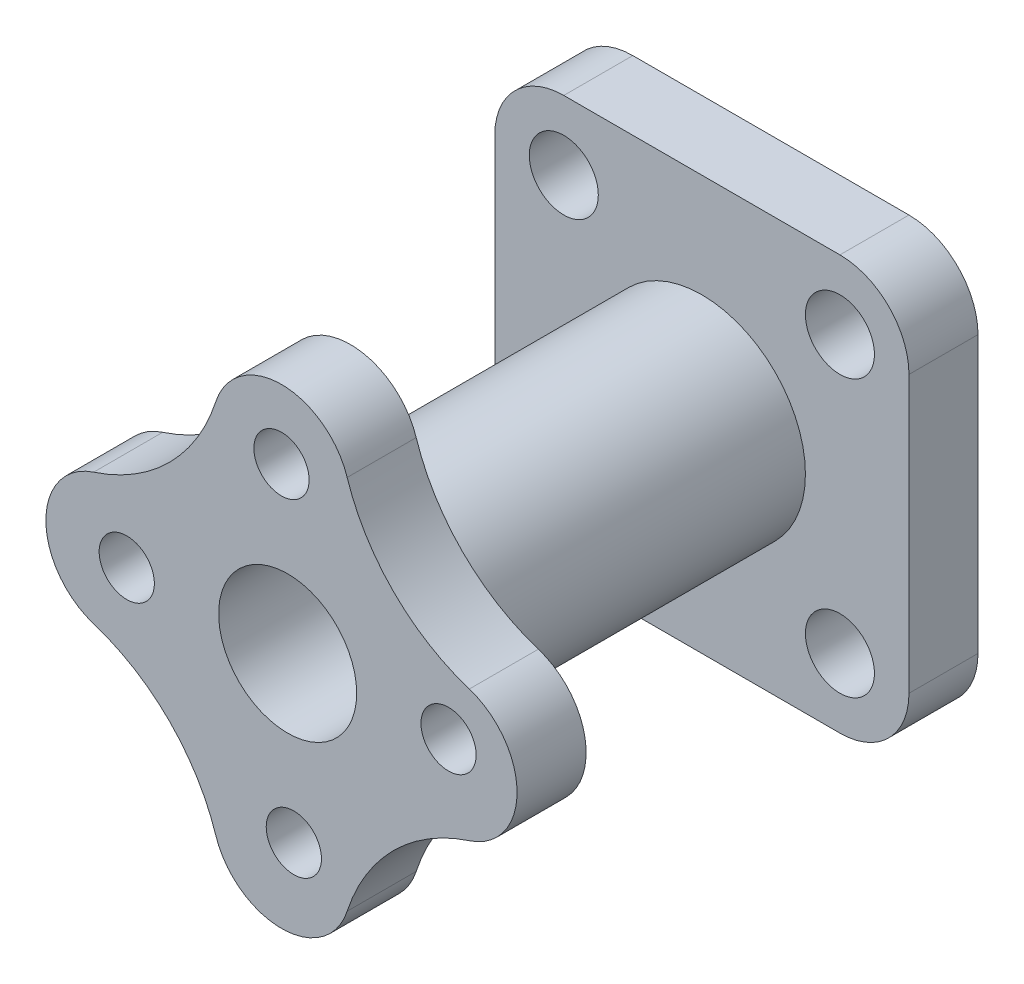
from build123d import *

# Parameters (mm, degrees)
SCHIZZO1_W                   = 120
SCHIZZO1_H                   = 120
ESTRUSIONE_ESTRUSIONE1_DEPTH = 20
SCHIZZO3_R                   = 30
SCHIZZO3_R_2                 = 20
ESTRUSIONE_ESTRUSIONE2_DEPTH = 100
SCHIZZO4_R                   = 20
ESTRUSIONE_ESTRUSIONE3_DEPTH = 20
RACCORDO2_R                  = 20
SCHIZZO8_R                   = 8
TAGLIO_ESTRUSIONE1_DEPTH     = 20
SCHIZZO7_R                   = 10
TAGLIO_ESTRUSIONE2_DEPTH     = 20
RIPETIZIONECIRCOLARE1_COUNT  = 4


with BuildPart() as part:
    # Schizzo1 → Estrusione-Estrusione1 (new body)
    with BuildSketch(Plane.XY):
        Rectangle(SCHIZZO1_W, SCHIZZO1_H)
    extrude(amount=ESTRUSIONE_ESTRUSIONE1_DEPTH)

    # Schizzo3 → Estrusione-Estrusione2 (add)
    with BuildSketch(Plane.XY.offset(20)):
        Circle(SCHIZZO3_R)
        Circle(SCHIZZO3_R_2, mode=Mode.SUBTRACT)
    extrude(amount=ESTRUSIONE_ESTRUSIONE2_DEPTH)

    # Schizzo4 → Estrusione-Estrusione3 (add)
    with BuildSketch(Plane.XY.offset(120)):
        with BuildLine():
            ThreePointArc((-56.205527859, 17.383404463), (-34.252252481, 30.819558816), (-20.816098128, 52.772834194))
            ThreePointArc((-20.816098128, 52.772834194), (-1.788088194, 66.613707799), (17.23992174, 52.772834194))
            ThreePointArc((17.23992174, 52.772834194), (30.676076093, 30.819558816), (52.629351472, 17.383404463))
            ThreePointArc((52.629351472, 17.383404463), (66.470225076, -1.644605471), (52.629351472, -20.672615405))
            ThreePointArc((52.629351472, -20.672615405), (30.676076093, -34.108769758), (17.23992174, -56.062045137))
            ThreePointArc((17.23992174, -56.062045137), (-1.788088194, -69.902918741), (-20.816098128, -56.062045137))
            ThreePointArc((-20.816098128, -56.062045137), (-34.252252481, -34.108769758), (-56.205527859, -20.672615405))
            ThreePointArc((-56.205527859, -20.672615405), (-70.046401464, -1.644605471), (-56.205527859, 17.383404463))
        make_face()
        Circle(SCHIZZO4_R, mode=Mode.SUBTRACT)
    extrude(amount=ESTRUSIONE_ESTRUSIONE3_DEPTH)

    # Raccordo2
    raccordo2_edges = [part.edges().sort_by_distance(p)[0] for p in [
        (-60, 60, 10),
        (60, 60, 10),
        (60, -60, 10),
        (-60, -60, 10),
    ]]
    fillet(raccordo2_edges, radius=RACCORDO2_R)

    # Schizzo8 → Taglio-Estrusione1 (cut)
    with BuildSketch(Plane.XY.offset(140)):
        with Locations((-1.788088194, 46.613707799)):
            Circle(SCHIZZO8_R)
    taglio_estrusione1 = extrude(amount=-TAGLIO_ESTRUSIONE1_DEPTH, mode=Mode.SUBTRACT)

    # Schizzo7 → Taglio-Estrusione2 (cut)
    with BuildSketch(Plane(origin=(0, 0, 0), x_dir=(-1, 0, 0), z_dir=(0, 0, -1))):
        with Locations((-40, 40)):
            Circle(SCHIZZO7_R)
    taglio_estrusione2 = extrude(amount=-TAGLIO_ESTRUSIONE2_DEPTH, mode=Mode.SUBTRACT)

    # RipetizioneCircolare1: Taglio-Estrusione1, Taglio-Estrusione2 ×4 about axis
    ripetizionecircolare1_axis = Axis((0, 0, 0), (0, 0, 1))
    for i in range(1, RIPETIZIONECIRCOLARE1_COUNT):
        add(taglio_estrusione1.rotate(ripetizionecircolare1_axis, i * 360 / RIPETIZIONECIRCOLARE1_COUNT), mode=Mode.SUBTRACT)
        add(taglio_estrusione2.rotate(ripetizionecircolare1_axis, i * 360 / RIPETIZIONECIRCOLARE1_COUNT), mode=Mode.SUBTRACT)


solid = part.part
